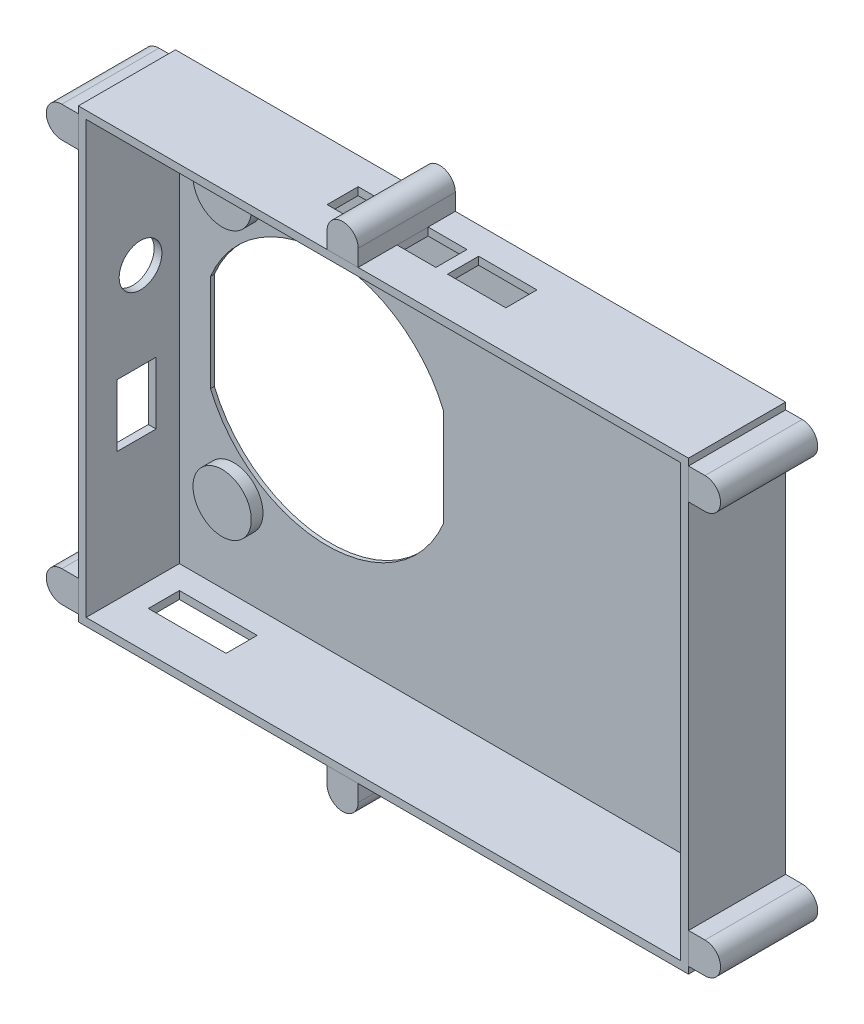
from build123d import *

# Parameters (mm, degrees)
SKETCH1_W             = 157
SKETCH1_H             = 115
BOSS_EXTRUDE1_DEPTH   = 1
SKETCH2_W             = 2
SKETCH2_H             = 111
BOSS_EXTRUDE2_DEPTH   = 24
CUT_EXTRUDE1_REACH    = 159
SKETCH4_R             = 5.5
SKETCH4_W             = 10
SKETCH4_H             = 16
CUT_EXTRUDE2_REACH    = 117
SKETCH5_W             = 20
SKETCH5_H             = 8
CUT_EXTRUDE3_REACH    = 117
SKETCH6_W             = 10
SKETCH6_H             = 8
SKETCH6_W_2           = 15
SKETCH8_R             = 7.5
BOSS_EXTRUDE3_DEPTH   = 4
CUT_EXTRUDE5_REACH    = 27
BOSS_EXTRUDE5_DEPTH   = 25
BOSS_EXTRUDE5_2_DEPTH = 25
BOSS_EXTRUDE5_3_DEPTH = 25
BOSS_EXTRUDE5_4_DEPTH = 25
BOSS_EXTRUDE5_5_DEPTH = 25
BOSS_EXTRUDE5_6_DEPTH = 25


with BuildPart() as part:
    # Sketch1 → Boss-Extrude1 (new body)
    with BuildSketch(Plane.XY):
        Rectangle(SKETCH1_W, SKETCH1_H)
    extrude(amount=BOSS_EXTRUDE1_DEPTH)

    # Sketch2 → Boss-Extrude2 (add)
    with BuildSketch(Plane.XY.offset(1)):
        with Locations((-77.5, 0)):
            Rectangle(SKETCH2_W, SKETCH2_H)
        Polygon((78.5, 57.5), (-78.5, 57.5), (-78.5, 55.5), (-76.5, 55.5), (76.5, 55.5), (78.5, 55.5), align=None)
        with Locations((77.5, 0)):
            Rectangle(SKETCH2_W, SKETCH2_H)
        Polygon((-76.5, -55.5), (-78.5, -55.5), (-78.5, -57.5), (78.5, -57.5), (78.5, -55.5), (76.5, -55.5), align=None)
    extrude(amount=BOSS_EXTRUDE2_DEPTH)

    # Sketch4 → Cut-Extrude1 (cut, up to next)
    with BuildSketch(Plane.ZY.offset(78.5), mode=Mode.PRIVATE) as cut_extrude1_sk1:
        with Locations((11, 16)):
            Circle(SKETCH4_R)
    cut_extrude1_tool1 = extrude(cut_extrude1_sk1.sketch, amount=-CUT_EXTRUDE1_REACH, mode=Mode.PRIVATE) & part.part
    add(cut_extrude1_tool1.solids().sort_by_distance((-78.5, 16, 11))[0], mode=Mode.SUBTRACT)
    # Sketch4 → Cut-Extrude1 (cut, up to next)
    with BuildSketch(Plane.ZY.offset(78.5), mode=Mode.PRIVATE) as cut_extrude1_sk2:
        with Locations((12, -14.5)):
            Rectangle(SKETCH4_W, SKETCH4_H)
    cut_extrude1_tool2 = extrude(cut_extrude1_sk2.sketch, amount=-CUT_EXTRUDE1_REACH, mode=Mode.PRIVATE) & part.part
    add(cut_extrude1_tool2.solids().sort_by_distance((-78.5, -14.5, 12))[0], mode=Mode.SUBTRACT)

    # Sketch5 → Cut-Extrude2 (cut, up to next)
    with BuildSketch(Plane.XZ.offset(57.5), mode=Mode.PRIVATE) as cut_extrude2_sk1:
        with Locations((-60.5, 11)):
            Rectangle(SKETCH5_W, SKETCH5_H)
    cut_extrude2_tool1 = extrude(cut_extrude2_sk1.sketch, amount=-CUT_EXTRUDE2_REACH, mode=Mode.PRIVATE) & part.part
    add(cut_extrude2_tool1.solids().sort_by_distance((-60.5, -57.5, 11))[0], mode=Mode.SUBTRACT)

    # Sketch6 → Cut-Extrude3 (cut, up to next)
    with BuildSketch(Plane(origin=(0, 57.5, 0), x_dir=(1, 0, 0), z_dir=(0, 1, 0)), mode=Mode.PRIVATE) as cut_extrude3_sk1:
        with Locations((-19.5, -11)):
            Rectangle(SKETCH6_W, SKETCH6_H)
    cut_extrude3_tool1 = extrude(cut_extrude3_sk1.sketch, amount=-CUT_EXTRUDE3_REACH, mode=Mode.PRIVATE) & part.part
    add(cut_extrude3_tool1.solids().sort_by_distance((-19.5, 57.5, 11))[0], mode=Mode.SUBTRACT)
    # Sketch6 → Cut-Extrude3 (cut, up to next)
    with BuildSketch(Plane(origin=(0, 57.5, 0), x_dir=(1, 0, 0), z_dir=(0, 1, 0)), mode=Mode.PRIVATE) as cut_extrude3_sk2:
        with Locations((-1.5, -11)):
            Rectangle(SKETCH6_W, SKETCH6_H)
    cut_extrude3_tool2 = extrude(cut_extrude3_sk2.sketch, amount=-CUT_EXTRUDE3_REACH, mode=Mode.PRIVATE) & part.part
    add(cut_extrude3_tool2.solids().sort_by_distance((-1.5, 57.5, 11))[0], mode=Mode.SUBTRACT)
    # Sketch6 → Cut-Extrude3 (cut, up to next)
    with BuildSketch(Plane(origin=(0, 57.5, 0), x_dir=(1, 0, 0), z_dir=(0, 1, 0)), mode=Mode.PRIVATE) as cut_extrude3_sk3:
        with Locations((14, -11)):
            Rectangle(SKETCH6_W_2, SKETCH6_H)
    cut_extrude3_tool3 = extrude(cut_extrude3_sk3.sketch, amount=-CUT_EXTRUDE3_REACH, mode=Mode.PRIVATE) & part.part
    add(cut_extrude3_tool3.solids().sort_by_distance((14, 57.5, 11))[0], mode=Mode.SUBTRACT)

    # Sketch8 → Boss-Extrude3 (add)
    with BuildSketch(Plane(origin=(0, 0, 0), x_dir=(-1, 0, 0), z_dir=(0, 0, -1))):
        with Locations((-64.5, 35.5)):
            Circle(SKETCH8_R)
        with Locations((62.5, 35.5)):
            Circle(SKETCH8_R)
        with Locations((62.5, -33.5)):
            Circle(SKETCH8_R)
        with Locations((-64.5, -38.5)):
            Circle(SKETCH8_R)
    extrude(amount=-BOSS_EXTRUDE3_DEPTH)

    # Sketch9 → Cut-Extrude5 (cut, up to next)
    with BuildSketch(Plane(origin=(0, 0, 0), x_dir=(-1, 0, 0), z_dir=(0, 0, -1)), mode=Mode.PRIVATE) as cut_extrude5_sk1:
        with BuildLine():
            Line((8.5, 12.5), (8.5, -12.5))
            ThreePointArc((8.5, -12.5), (38.5, -32.5), (68.5, -12.5))
            Line((68.5, -12.5), (68.5, 12.5))
            ThreePointArc((68.5, 12.5), (38.5, 32.5), (8.5, 12.5))
        make_face()
    cut_extrude5_tool1 = extrude(cut_extrude5_sk1.sketch, amount=-CUT_EXTRUDE5_REACH, mode=Mode.PRIVATE) & part.part
    add(cut_extrude5_tool1.solids().sort_by_distance((-38.5, 0, 0))[0], mode=Mode.SUBTRACT)


with BuildPart() as body_2:
    # Sketch13 → Boss-Extrude5 (new body)
    with BuildSketch(Plane(origin=(0, 0, 0), x_dir=(-1, 0, 0), z_dir=(0, 0, -1))):
        with BuildLine():
            Line((-82.75, -55.75), (-78.5, -55.75))
            Line((-78.5, -55.75), (-78.5, -47.75))
            Line((-78.5, -47.75), (-82.75, -47.75))
            ThreePointArc((-82.75, -47.75), (-86.75, -51.75), (-82.75, -55.75))
        make_face()
    extrude(amount=-BOSS_EXTRUDE5_DEPTH)


with BuildPart() as body_3:
    # Sketch13 → Boss-Extrude5 2 (new body)
    with BuildSketch(Plane(origin=(0, 0, 0), x_dir=(-1, 0, 0), z_dir=(0, 0, -1))):
        with BuildLine():
            Line((-78.5, 47.75), (-78.5, 55.75))
            Line((-78.5, 55.75), (-82.75, 55.75))
            ThreePointArc((-82.75, 55.75), (-86.75, 51.75), (-82.75, 47.75))
            Line((-82.75, 47.75), (-78.5, 47.75))
        make_face()
    extrude(amount=-BOSS_EXTRUDE5_2_DEPTH)


with BuildPart() as body_4:
    # Sketch13 → Boss-Extrude5 3 (new body)
    with BuildSketch(Plane(origin=(0, 0, 0), x_dir=(-1, 0, 0), z_dir=(0, 0, -1))):
        with BuildLine():
            Line((78.5, -47.75), (78.5, -55.75))
            Line((78.5, -55.75), (82.75, -55.75))
            ThreePointArc((82.75, -55.75), (86.75, -51.75), (82.75, -47.75))
            Line((82.75, -47.75), (78.5, -47.75))
        make_face()
    extrude(amount=-BOSS_EXTRUDE5_3_DEPTH)


with BuildPart() as body_5:
    # Sketch13 → Boss-Extrude5 4 (new body)
    with BuildSketch(Plane(origin=(0, 0, 0), x_dir=(-1, 0, 0), z_dir=(0, 0, -1))):
        with BuildLine():
            Line((82.75, 55.75), (78.5, 55.75))
            Line((78.5, 55.75), (78.5, 47.75))
            Line((78.5, 47.75), (82.75, 47.75))
            ThreePointArc((82.75, 47.75), (86.75, 51.75), (82.75, 55.75))
        make_face()
    extrude(amount=-BOSS_EXTRUDE5_4_DEPTH)


with BuildPart() as body_6:
    # Sketch13 → Boss-Extrude5 5 (new body)
    with BuildSketch(Plane(origin=(0, 0, 0), x_dir=(-1, 0, 0), z_dir=(0, 0, -1))):
        with BuildLine():
            Line((6.5, 57.5), (14.5, 57.5))
            Line((14.5, 57.5), (14.5, 61.75))
            ThreePointArc((14.5, 61.75), (10.5, 65.75), (6.5, 61.75))
            Line((6.5, 61.75), (6.5, 57.5))
        make_face()
    extrude(amount=-BOSS_EXTRUDE5_5_DEPTH)


with BuildPart() as body_7:
    # Sketch13 → Boss-Extrude5 6 (new body)
    with BuildSketch(Plane(origin=(0, 0, 0), x_dir=(-1, 0, 0), z_dir=(0, 0, -1))):
        with BuildLine():
            Line((14.5, -61.75), (14.5, -57.5))
            Line((14.5, -57.5), (6.5, -57.5))
            Line((6.5, -57.5), (6.5, -61.75))
            ThreePointArc((6.5, -61.75), (10.5, -65.75), (14.5, -61.75))
        make_face()
    extrude(amount=-BOSS_EXTRUDE5_6_DEPTH)


solid = Compound([part.part, body_2.part, body_3.part, body_4.part, body_5.part, body_6.part, body_7.part])
